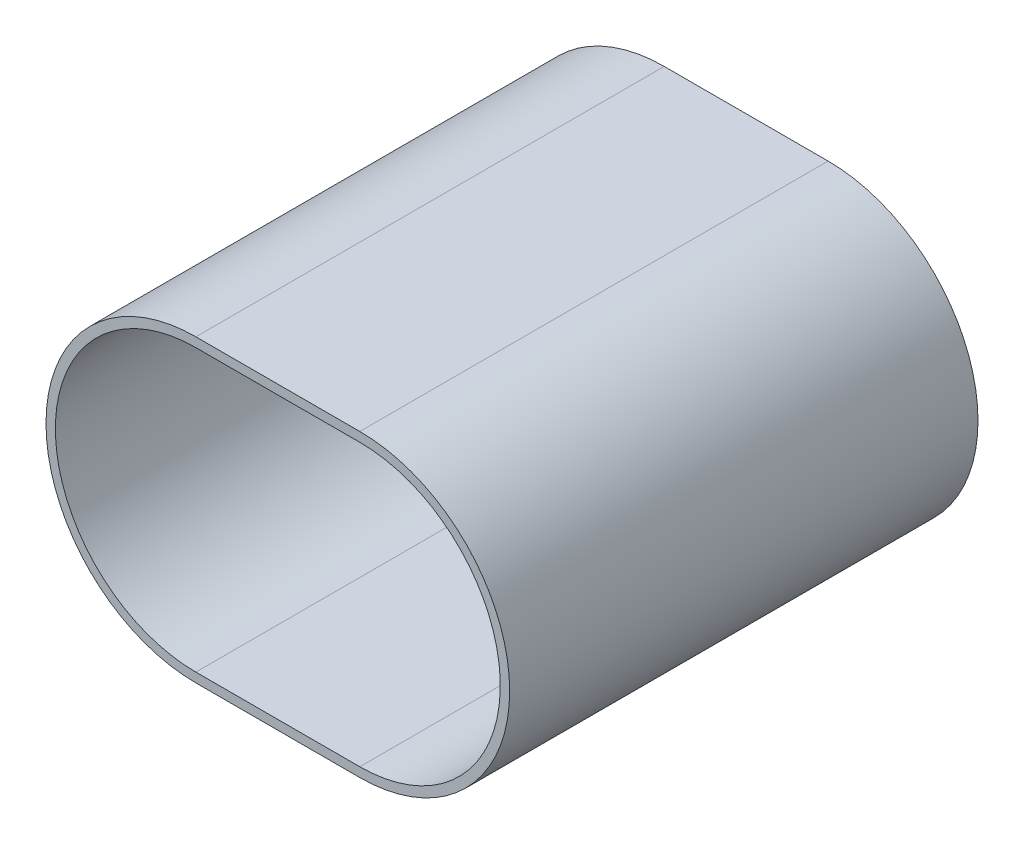
from build123d import *

# Parameters (mm, degrees)
BOSS_EXTRUDE1_DEPTH = 100


with BuildPart() as part:
    # Sketch1 → Boss-Extrude1 (new body)
    with BuildSketch(Plane.XY):
        with BuildLine():
            Line((0, 32), (35, 32))
            ThreePointArc((35, 32), (67, 0), (35, -32))
            Line((35, -32), (0, -32))
            ThreePointArc((0, -32), (-32, 0), (0, 32))
        make_face()
        with BuildLine():
            Line((0, 30), (35, 30))
            ThreePointArc((35, 30), (65, 0), (35, -30))
            Line((35, -30), (0, -30))
            ThreePointArc((0, -30), (-30, 0), (0, 30))
        make_face(mode=Mode.SUBTRACT)
    extrude(amount=BOSS_EXTRUDE1_DEPTH)


solid = part.part
